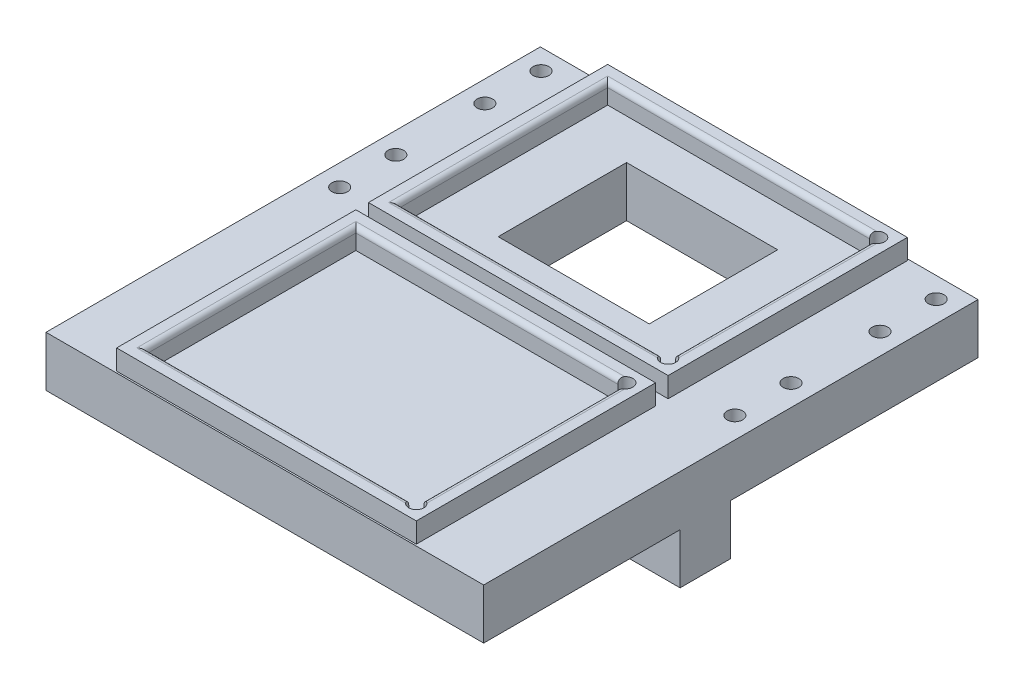
from build123d import *

# Parameters (mm, degrees)
SKETCH1_R           = 1.55
SKETCH1_W           = 30
SKETCH1_H           = 25.5
BOSS_EXTRUDE1_DEPTH = 10
SKETCH2_W           = 59.5
SKETCH2_H           = 47.5
SKETCH2_W_2         = 53.5
SKETCH2_H_2         = 41.5
BOSS_EXTRUDE2_DEPTH = 4
CUT_EXTRUDE1_REACH  = 16
SKETCH3_R           = 1.5
FILLET2_R           = 1
SKETCH6_W           = 86.9
SKETCH6_H           = 10
BOSS_EXTRUDE3_DEPTH = 10
CUT_EXTRUDE2_REACH  = 61.15
SKETCH7_R           = 1.55


with BuildPart() as part:
    # Sketch1 → Boss-Extrude1 (new body)
    with BuildSketch(Plane(origin=(0, 0, 0), x_dir=(1, 0, 0), z_dir=(0, 1, 0))):
        Polygon((-43.45, 24.075), (43.45, 24.075), (43.45, -24.075), (43.45, -74.075), (-43.45, -74.075), (-43.45, -24.075), align=None)
        with Locations((-39.23, 19.985)):
            Circle(SKETCH1_R, mode=Mode.SUBTRACT)
        with Locations((-39.23, 8.835)):
            Circle(SKETCH1_R, mode=Mode.SUBTRACT)
        with Locations((-39.23, -8.835)):
            Circle(SKETCH1_R, mode=Mode.SUBTRACT)
        with Locations((-39.23, -19.985)):
            Circle(SKETCH1_R, mode=Mode.SUBTRACT)
        with Locations((39.23, -19.985)):
            Circle(SKETCH1_R, mode=Mode.SUBTRACT)
        with Locations((39.23, -8.835)):
            Circle(SKETCH1_R, mode=Mode.SUBTRACT)
        with Locations((39.23, 8.835)):
            Circle(SKETCH1_R, mode=Mode.SUBTRACT)
        with Locations((39.23, 19.985)):
            Circle(SKETCH1_R, mode=Mode.SUBTRACT)
        Rectangle(SKETCH1_W, SKETCH1_H, mode=Mode.SUBTRACT)
    extrude(amount=BOSS_EXTRUDE1_DEPTH)

    # Sketch2 → Boss-Extrude2 (add)
    with BuildSketch(Plane(origin=(0, 10, 0), x_dir=(1, 0, 0), z_dir=(0, 1, 0))):
        with Locations((0, -50)):
            Rectangle(SKETCH2_W, SKETCH2_H)
        with Locations((0, -50)):
            Rectangle(SKETCH2_W_2, SKETCH2_H_2, mode=Mode.SUBTRACT)
        Rectangle(SKETCH2_W, SKETCH2_H)
        Rectangle(SKETCH2_W_2, SKETCH2_H_2, mode=Mode.SUBTRACT)
    extrude(amount=BOSS_EXTRUDE2_DEPTH)

    # Sketch3 → Cut-Extrude1 (cut, up to next)
    with BuildSketch(Plane(origin=(0, 14, 0), x_dir=(1, 0, 0), z_dir=(0, 1, 0)), mode=Mode.PRIVATE) as cut_extrude1_sk1:
        with Locations((26.75, 20.75)):
            Circle(SKETCH3_R)
    cut_extrude1_tool1 = extrude(cut_extrude1_sk1.sketch, amount=-CUT_EXTRUDE1_REACH, mode=Mode.PRIVATE) & part.part
    add(cut_extrude1_tool1.solids().sort_by_distance((26.75, 14, -20.75))[0], mode=Mode.SUBTRACT)
    # Sketch3 → Cut-Extrude1 (cut, up to next)
    with BuildSketch(Plane(origin=(0, 14, 0), x_dir=(1, 0, 0), z_dir=(0, 1, 0)), mode=Mode.PRIVATE) as cut_extrude1_sk2:
        with Locations((26.75, -20.75)):
            Circle(SKETCH3_R)
    cut_extrude1_tool2 = extrude(cut_extrude1_sk2.sketch, amount=-CUT_EXTRUDE1_REACH, mode=Mode.PRIVATE) & part.part
    add(cut_extrude1_tool2.solids().sort_by_distance((26.75, 14, 20.75))[0], mode=Mode.SUBTRACT)
    # Sketch3 → Cut-Extrude1 (cut, up to next)
    with BuildSketch(Plane(origin=(0, 14, 0), x_dir=(1, 0, 0), z_dir=(0, 1, 0)), mode=Mode.PRIVATE) as cut_extrude1_sk3:
        with Locations((26.75, -29.25)):
            Circle(SKETCH3_R)
    cut_extrude1_tool3 = extrude(cut_extrude1_sk3.sketch, amount=-CUT_EXTRUDE1_REACH, mode=Mode.PRIVATE) & part.part
    add(cut_extrude1_tool3.solids().sort_by_distance((26.75, 14, 29.25))[0], mode=Mode.SUBTRACT)
    # Sketch3 → Cut-Extrude1 (cut, up to next)
    with BuildSketch(Plane(origin=(0, 14, 0), x_dir=(1, 0, 0), z_dir=(0, 1, 0)), mode=Mode.PRIVATE) as cut_extrude1_sk4:
        with Locations((26.75, -70.75)):
            Circle(SKETCH3_R)
    cut_extrude1_tool4 = extrude(cut_extrude1_sk4.sketch, amount=-CUT_EXTRUDE1_REACH, mode=Mode.PRIVATE) & part.part
    add(cut_extrude1_tool4.solids().sort_by_distance((26.75, 14, 70.75))[0], mode=Mode.SUBTRACT)

    # Fillet2
    fillet2_edges = [part.edges().sort_by_distance(p)[0] for p in [
        (-26.75, 14, 50),
        (-0.75, 14, 29.25),
        (26.75, 14, 50),
        (-0.75, 14, -20.75),
        (26.75, 14, 0),
        (-26.75, 14, 0),
        (-0.75, 14, 20.75),
        (-0.75, 14, 70.75),
    ]]
    fillet(fillet2_edges, radius=FILLET2_R)

    # Sketch6 → Boss-Extrude3 (add)
    with BuildSketch(Plane.XZ):
        with Locations((0, 30.075)):
            Rectangle(SKETCH6_W, SKETCH6_H)
    extrude(amount=BOSS_EXTRUDE3_DEPTH)

    # Sketch7 → Cut-Extrude2 (cut, up to next)
    with BuildSketch(Plane.XY.offset(35.075), mode=Mode.PRIVATE) as cut_extrude2_sk1:
        with Locations((-33.45, -5)):
            Circle(SKETCH7_R)
    cut_extrude2_tool1 = extrude(cut_extrude2_sk1.sketch, amount=-CUT_EXTRUDE2_REACH, mode=Mode.PRIVATE) & part.part
    add(cut_extrude2_tool1.solids().sort_by_distance((-33.45, -5, 35.075))[0], mode=Mode.SUBTRACT)
    # Sketch7 → Cut-Extrude2 (cut, up to next)
    with BuildSketch(Plane.XY.offset(35.075), mode=Mode.PRIVATE) as cut_extrude2_sk2:
        with Locations((33.45, -5)):
            Circle(SKETCH7_R)
    cut_extrude2_tool2 = extrude(cut_extrude2_sk2.sketch, amount=-CUT_EXTRUDE2_REACH, mode=Mode.PRIVATE) & part.part
    add(cut_extrude2_tool2.solids().sort_by_distance((33.45, -5, 35.075))[0], mode=Mode.SUBTRACT)


solid = part.part
